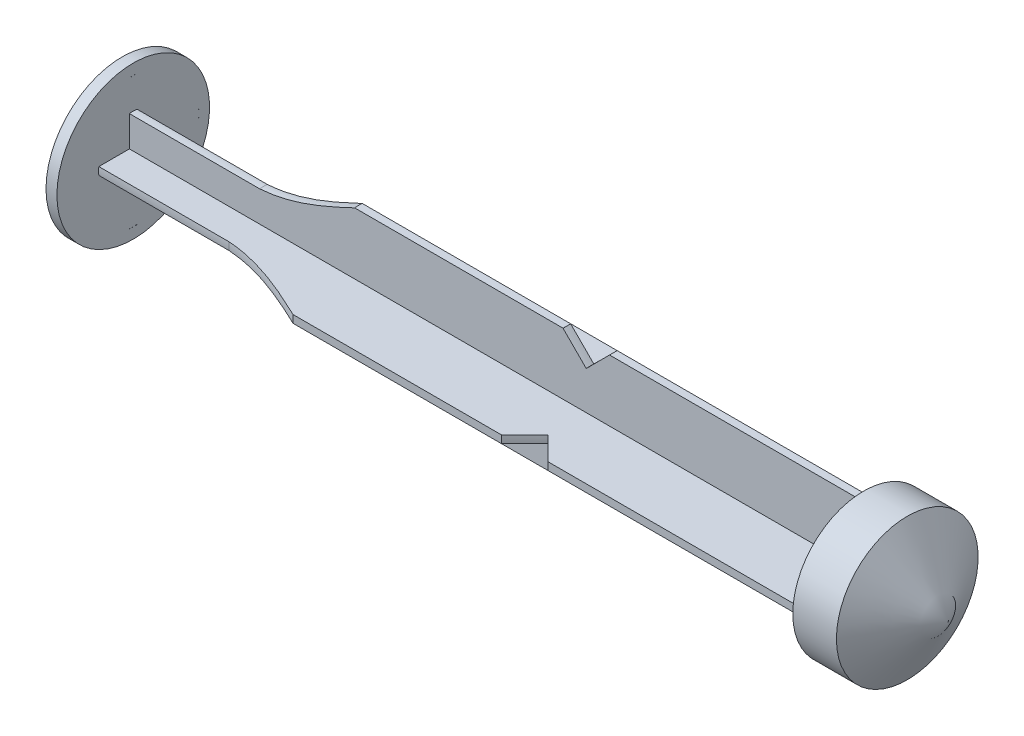
from build123d import *

# Parameters (mm, degrees)
EXTRUDE_1_DEPTH = 67
SKETCH_3_W      = 1
SKETCH_3_H      = 7


with BuildPart() as part:
    # Эскиз1 → Бобышка-Вытянуть1 (new body)
    with BuildSketch(Plane(origin=(0, 0, 0), x_dir=(0, 0, -1), z_dir=(1, 0, 0))):
        Polygon((-6, 0.35), (-0.35, 0.35), (-0.35, 6), (0.35, 6), (0.35, 0.35), (6, 0.35), (6, -0.35), (0.35, -0.35), (0.35, -6), (-0.35, -6), (-0.35, -0.35), (-6, -0.35), align=None)
    extrude(amount=EXTRUDE_1_DEPTH)

    # Эскиз3 → Повернуть1 (revolve)
    with BuildSketch(Plane.XY):
        Polygon((74.75277675, 0), (71, 6.5), (67, 6.5), (67, 0), align=None)
        with Locations((-0.5, 3.5)):
            Rectangle(SKETCH_3_W, SKETCH_3_H)
    revolve(axis=Axis((0, 0, 0), (1, 0, 0)))

    # Эскиз4 → Вырез-Повернуть1 (revolve, cut)
    with BuildSketch(Plane.XY):
        with BuildLine():
            Line((0, 6), (0, 3.175))
            Line((0, 3.175), (11.953250745, 3.175))
            add(Edge.make_bspline(
                [(11.953250745, 3.175), (13.82559534, 3.302015048), (23.044496857, 6.133590622), (30.696517759, 12.611861304), (39.780139318, 8.557592838)],
                knots=[0, 0, 0, 0, 0.195436417, 1, 1, 1, 1], degree=3))
            Line((39.780139318, 8.557592838), (39.780139318, 6))
            Line((39.780139318, 6), (41.904336104, 3.875803214))
            Line((41.904336104, 3.875803214), (45.076323965, 7.047791075))
            Line((45.076323965, 7.047791075), (24.996442716, 20.783696601))
            Line((24.996442716, 20.783696601), (10.913533525, 15.605616348))
            Line((10.913533525, 15.605616348), (0, 6))
        make_face()
    revolve(axis=Axis((0, 0, 0), (1, 0, 0)), mode=Mode.SUBTRACT)


solid = part.part
